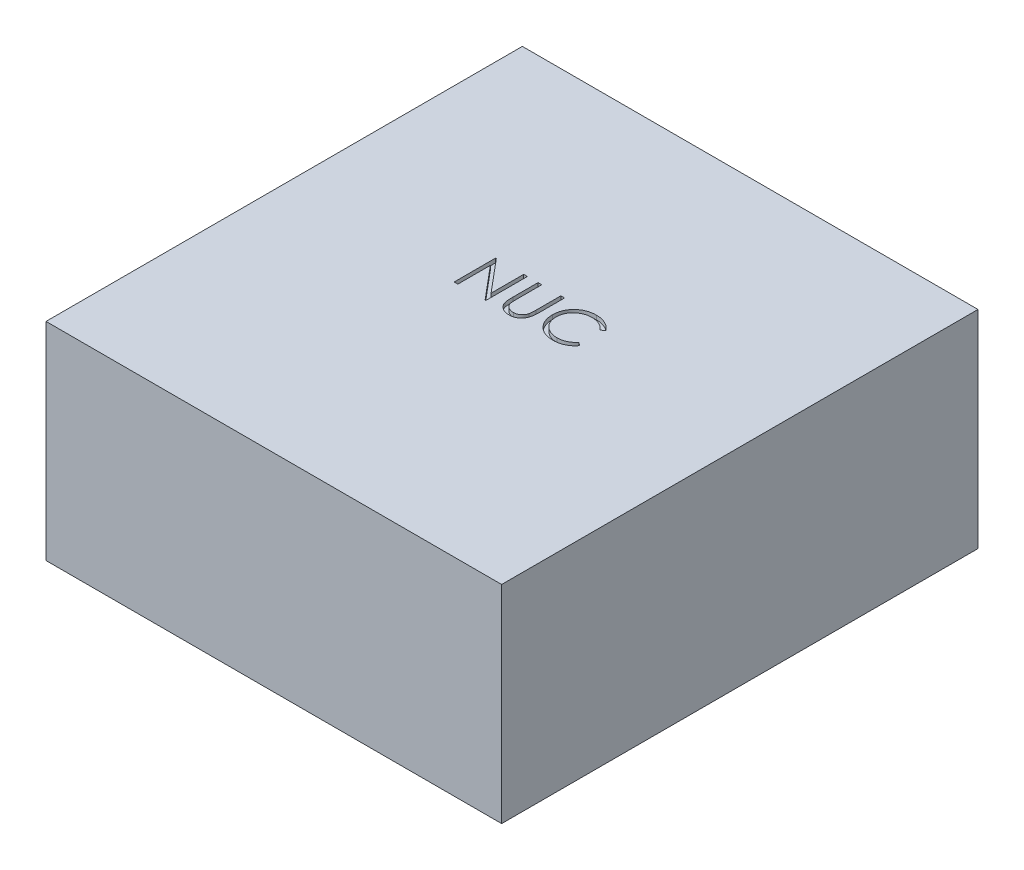
from build123d import *

# Parameters (mm, degrees)
SKETCH1_W           = 110
SKETCH1_H           = 115
BOSS_EXTRUDE1_DEPTH = 50
CUT_EXTRUDE1_DEPTH  = 1


with BuildPart() as part:
    # Sketch1 → Boss-Extrude1 (new body)
    with BuildSketch(Plane(origin=(0, 0, 0), x_dir=(1, 0, 0), z_dir=(0, 1, 0))):
        with Locations((55, 57.5)):
            Rectangle(SKETCH1_W, SKETCH1_H)
    extrude(amount=BOSS_EXTRUDE1_DEPTH)

    # Sketch2 → Cut-Extrude1 (cut)
    with BuildSketch(Plane(origin=(0, 50, 0), x_dir=(1, 0, 0), z_dir=(0, 1, 0))):
        Polygon((41.025641026, 57.5), (41.025641026, 67.5), (41.213942308, 67.5), (47.820512821, 59.629407051), (47.820512821, 67.5), (48.717948718, 67.5), (48.717948718, 57.5), (48.513621795, 57.5), (41.923076923, 65.352564103), (41.923076923, 57.5), align=None)
        with BuildLine():
            Line((51.282051282, 67.5), (52.179487179, 67.5))
            Line((52.179487179, 67.5), (52.179487179, 61.508413462))
            add(Edge.make_bspline(
                [(52.179487179, 61.508413462), (52.179353625, 61.423611359), (52.179100183, 61.262684757), (52.18079308, 61.033632469), (52.185534133, 60.829996872), (52.18852316, 60.650993022), (52.195172684, 60.497442315), (52.200595675, 60.368512856), (52.207568695, 60.264815135), (52.21594903, 60.204298203), (52.219551282, 60.178285256)],
                knots=[0, 0, 0, 0, 1.528628734, 2.90083645, 4.128790002, 5.200304208, 6.127813768, 6.898992206, 7.526736466, 8, 8, 8, 8], degree=3))
            add(Edge.make_bspline(
                [(52.219551282, 60.178285256), (52.234344021, 60.084437361), (52.263095982, 59.902029564), (52.336371348, 59.642291615), (52.438707065, 59.408201735), (52.559972901, 59.192455189), (52.719780362, 59.001057017), (52.911219034, 58.824738009), (53.143155516, 58.670532853), (53.401042961, 58.529530533), (53.679000782, 58.416201727), (53.963032972, 58.3305064), (54.248870055, 58.278280972), (54.440230527, 58.272233718), (54.53525641, 58.269230769)],
                knots=[0, 0, 0, 0, 1.035780045, 2.013197591, 2.933192213, 3.817615948, 4.702609284, 5.640816605, 6.646850145, 7.73207398, 8.84249596, 9.914020372, 10.964143139, 12, 12, 12, 12], degree=3))
            add(Edge.make_bspline(
                [(54.53525641, 58.269230769), (54.616838526, 58.272298913), (54.77953156, 58.278417479), (55.021264219, 58.316307282), (55.256693101, 58.384594613), (55.486980758, 58.472708208), (55.702840713, 58.589129897), (55.904393404, 58.72361801), (56.084290359, 58.88136337), (56.248456067, 59.055935783), (56.391413027, 59.25290664), (56.515330574, 59.467987034), (56.616833231, 59.70441374), (56.666957587, 59.870569232), (56.692708333, 59.955929487)],
                knots=[0, 0, 0, 0, 0.994687771, 1.983630487, 2.973142513, 3.978332533, 4.983357753, 5.956394766, 6.925816176, 7.893390482, 8.871859704, 9.88551698, 10.913711441, 12, 12, 12, 12], degree=3))
            add(Edge.make_bspline(
                [(56.692708333, 59.955929487), (56.70128012, 59.991211128), (56.720381515, 60.069832843), (56.738230215, 60.202750816), (56.756820287, 60.35957757), (56.769719059, 60.541439892), (56.782293974, 60.747728385), (56.789817039, 60.979517692), (56.793294276, 61.235966152), (56.794330506, 61.414929471), (56.794871795, 61.508413462)],
                knots=[0, 0, 0, 0, 0.558680831, 1.244966039, 2.062412453, 2.990489873, 4.051219941, 5.244515665, 6.560634259, 8, 8, 8, 8], degree=3))
            Line((56.794871795, 61.508413462), (56.794871795, 67.5))
            Line((56.794871795, 67.5), (57.692307692, 67.5))
            Line((57.692307692, 67.5), (57.692307692, 61.460336538))
            add(Edge.make_bspline(
                [(57.692307692, 61.460336538), (57.691581634, 61.351484027), (57.690164687, 61.139051733), (57.677877326, 60.827762136), (57.658285898, 60.532467904), (57.630605646, 60.253129342), (57.593928494, 59.99074603), (57.55314215, 59.743018121), (57.501200627, 59.511723856), (57.440533767, 59.295059806), (57.371180772, 59.088815482), (57.28134892, 58.893076583), (57.180136063, 58.701892584), (57.060094197, 58.51815513), (56.925204533, 58.341050692), (56.772485445, 58.171653335), (56.606987842, 58.00725606), (56.425960529, 57.852075871), (56.2323876, 57.709765366), (56.026844864, 57.584628877), (55.810911236, 57.478847113), (55.585148018, 57.391773043), (55.349458867, 57.32630276), (55.103837839, 57.2775166), (54.847725859, 57.24979575), (54.673541127, 57.24567595), (54.585336538, 57.243589744)],
                knots=[0, 0, 0, 0, 1.316592851, 2.569410997, 3.76748051, 4.895814652, 5.963796859, 6.97159953, 7.931736103, 8.829262218, 9.692595152, 10.560224239, 11.431080259, 12.30701507, 13.211635791, 14.121146779, 15.063487852, 16.031507147, 17.00238618, 17.966455255, 18.938106653, 19.907068911, 20.888905087, 21.893141452, 22.933117798, 24, 24, 24, 24], degree=3))
            add(Edge.make_bspline(
                [(54.585336538, 57.243589744), (54.489139102, 57.24583193), (54.300400077, 57.250231092), (54.022291313, 57.275438949), (53.755679324, 57.322920076), (53.497748247, 57.383377058), (53.252009684, 57.466759165), (53.015171271, 57.564182378), (52.791289325, 57.683831694), (52.576731815, 57.816955674), (52.377232511, 57.966740354), (52.194097074, 58.129997994), (52.027023158, 58.304113358), (51.878826883, 58.490971546), (51.747052927, 58.68911928), (51.633538031, 58.899117108), (51.536071619, 59.120883726), (51.485767142, 59.275035727), (51.460336538, 59.352964744)],
                knots=[0, 0, 0, 0, 1.13879206, 2.234305948, 3.301075583, 4.341971843, 5.366689343, 6.369221514, 7.369726634, 8.367512178, 9.355451585, 10.318319045, 11.268648973, 12.207971039, 13.137398894, 14.081662264, 15.030215811, 16, 16, 16, 16], degree=3))
            add(Edge.make_bspline(
                [(51.460336538, 59.352964744), (51.445544658, 59.406200671), (51.41346074, 59.521670582), (51.379102746, 59.712774835), (51.350219656, 59.932817457), (51.323060918, 60.181813509), (51.307035324, 60.459955985), (51.292985499, 60.767124316), (51.281952303, 61.103689921), (51.282017367, 61.338131394), (51.282051282, 61.460336538)],
                knots=[0, 0, 0, 0, 0.625038921, 1.35572334, 2.194682327, 3.136881307, 4.189498639, 5.346923369, 6.617055217, 8, 8, 8, 8], degree=3))
            Line((51.282051282, 61.460336538), (51.282051282, 67.5))
        make_face()
        with BuildLine():
            Line((69.487179487, 65.665064103), (68.701923077, 65.064102564))
            add(Edge.make_bspline(
                [(68.701923077, 65.064102564), (68.645906253, 65.130862478), (68.534627834, 65.263482237), (68.355601541, 65.449709507), (68.169025418, 65.624181683), (67.974970786, 65.78772991), (67.76994473, 65.934634955), (67.558913877, 66.072552392), (67.338348034, 66.1961745), (67.033343077, 66.346068746), (66.634349225, 66.502486332), (66.132078256, 66.633638422), (65.607760832, 66.717127495), (65.250053405, 66.726169899), (65.068108974, 66.730769231)],
                knots=[0, 0, 0, 0, 0.757959112, 1.505699292, 2.245454638, 2.979532153, 3.711538275, 4.438200793, 5.171680507, 5.909471876, 7.393775596, 8.890124382, 10.418191784, 12, 12, 12, 12], degree=3))
            add(Edge.make_bspline(
                [(65.068108974, 66.730769231), (64.967870976, 66.729615052), (64.768325283, 66.727317407), (64.472186787, 66.697005621), (64.18157807, 66.654402163), (63.896688166, 66.591186954), (63.617879713, 66.511265185), (63.343329993, 66.415764003), (63.077013994, 66.297607317), (62.815247599, 66.167012289), (62.564449853, 66.019505304), (62.327149717, 65.858610013), (62.104212666, 65.68612688), (61.895462345, 65.501409433), (61.70068535, 65.305289546), (61.521293033, 65.095677142), (61.357906147, 64.87324236), (61.207286075, 64.640918339), (61.072392551, 64.399381791), (60.959450039, 64.147738733), (60.859435404, 63.890298438), (60.780294711, 63.624152265), (60.717653234, 63.351172934), (60.674431339, 63.070627825), (60.644464278, 62.783103026), (60.642178059, 62.588219276), (60.641025641, 62.489983974)],
                knots=[0, 0, 0, 0, 1.054917814, 2.100044995, 3.131103042, 4.146048494, 5.169673617, 6.183595914, 7.203665975, 8.234915748, 9.262203917, 10.264457458, 11.251630812, 12.227803204, 13.197192746, 14.159520551, 15.12972552, 16.100847026, 17.073214652, 18.039054194, 19.002613845, 19.979014051, 20.95965708, 21.949030935, 22.966165397, 24, 24, 24, 24], degree=3))
            add(Edge.make_bspline(
                [(60.641025641, 62.489983974), (60.644630838, 62.342180203), (60.651709165, 62.051987104), (60.714704405, 61.626928216), (60.810433237, 61.219726291), (60.953906314, 60.832926742), (61.130817887, 60.461760004), (61.354362492, 60.112506138), (61.613266884, 59.779887382), (61.911193797, 59.471764674), (62.238067557, 59.190296887), (62.588775876, 58.942438083), (62.962445269, 58.735824133), (63.354949927, 58.563892857), (63.769310252, 58.431730778), (64.204781116, 58.338690426), (64.660415389, 58.277998481), (64.971756531, 58.272187944), (65.130208333, 58.269230769)],
                knots=[0, 0, 0, 0, 1.029171465, 2.020641659, 2.987623507, 3.938342917, 4.889210282, 5.84687017, 6.821220943, 7.821438502, 8.827599549, 9.822697543, 10.807740252, 11.797342354, 12.80366471, 13.83203677, 14.896651826, 16, 16, 16, 16], degree=3))
            add(Edge.make_bspline(
                [(65.130208333, 58.269230769), (65.304787445, 58.274055854), (65.648400899, 58.283552776), (66.152309545, 58.364007773), (66.634697447, 58.494458967), (67.095590552, 58.677024459), (67.533689541, 58.914353853), (67.949679999, 59.202062075), (68.343913057, 59.542885882), (68.580973864, 59.803123392), (68.701923077, 59.935897436)],
                knots=[0, 0, 0, 0, 1.028121516, 2.023589091, 2.998037872, 3.967518031, 4.937445131, 5.927275754, 6.942489185, 8, 8, 8, 8], degree=3))
            Line((68.701923077, 59.935897436), (69.487179487, 59.340945513))
            add(Edge.make_bspline(
                [(69.487179487, 59.340945513), (69.423984888, 59.259407079), (69.297898387, 59.096720775), (69.093732624, 58.867373033), (68.878654631, 58.651647217), (68.651066889, 58.451282585), (68.413587484, 58.262269826), (68.161952306, 58.08997888), (67.899469356, 57.932004925), (67.627027988, 57.787356569), (67.344917665, 57.659021578), (67.053476423, 57.54915367), (66.753960493, 57.454511128), (66.446356183, 57.376648452), (66.130025449, 57.315873926), (65.806109809, 57.275246284), (65.473910165, 57.247412243), (65.249791819, 57.24487534), (65.136217949, 57.243589744)],
                knots=[0, 0, 0, 0, 0.986787822, 1.968848986, 2.935600012, 3.899624008, 4.868462664, 5.837806735, 6.815139263, 7.798259679, 8.787526145, 9.778297419, 10.776456485, 11.791383307, 12.812564526, 13.85620153, 14.913611965, 16, 16, 16, 16], degree=3))
            add(Edge.make_bspline(
                [(65.136217949, 57.243589744), (65.028664614, 57.244338294), (64.815991214, 57.245818459), (64.501994781, 57.26979608), (64.196310264, 57.302509614), (63.899811333, 57.351767132), (63.610879976, 57.409893817), (63.332135449, 57.487811693), (63.060834848, 57.575095027), (62.79806816, 57.677680703), (62.543611875, 57.793441225), (62.2982867, 57.92427425), (62.062205464, 58.069079578), (61.833047119, 58.224665322), (61.61419688, 58.396029041), (61.403758236, 58.580790854), (61.200551161, 58.778328028), (61.074829204, 58.920770466), (61.01161859, 58.992387821)],
                knots=[0, 0, 0, 0, 1.114604814, 2.203992996, 3.262667896, 4.300477797, 5.318619304, 6.316056647, 7.298880507, 8.271930387, 9.238335007, 10.195173496, 11.151986948, 12.108099108, 13.064862484, 14.031167946, 15.010108607, 16, 16, 16, 16], degree=3))
            add(Edge.make_bspline(
                [(61.01161859, 58.992387821), (60.910373894, 59.116791217), (60.709106817, 59.364096104), (60.451604864, 59.764913194), (60.231183278, 60.18339379), (60.052966362, 60.621736444), (59.913644267, 61.07895755), (59.817126567, 61.555287592), (59.754407697, 62.050281712), (59.747235443, 62.386958251), (59.743589744, 62.558092949)],
                knots=[0, 0, 0, 0, 0.994628077, 1.977248131, 2.950237994, 3.925870899, 4.908910175, 5.911660606, 6.938484602, 8, 8, 8, 8], degree=3))
            add(Edge.make_bspline(
                [(59.743589744, 62.558092949), (59.748033154, 62.737965673), (59.756775286, 63.091854029), (59.831048987, 63.611208181), (59.950531262, 64.108783607), (60.120236658, 64.583651448), (60.335394805, 65.038309392), (60.60118513, 65.469284263), (60.914519822, 65.879332262), (61.272941444, 66.262231551), (61.665990973, 66.612343987), (62.08690187, 66.920361712), (62.53485029, 67.176697472), (63.004901295, 67.390972222), (63.500574671, 67.555670688), (64.020812868, 67.670965507), (64.564638339, 67.742728697), (64.935673841, 67.751800719), (65.124198718, 67.756410256)],
                knots=[0, 0, 0, 0, 1.032925535, 2.032216505, 3.007276963, 3.968222605, 4.92396291, 5.891752235, 6.871517503, 7.883894988, 8.900124299, 9.891468569, 10.874487609, 11.85992873, 12.854644235, 13.869047385, 14.917252991, 16, 16, 16, 16], degree=3))
            add(Edge.make_bspline(
                [(65.124198718, 67.756410256), (65.239097209, 67.755032719), (65.466527201, 67.752306022), (65.802963351, 67.725717044), (66.130512857, 67.681392455), (66.449401377, 67.621060827), (66.76118028, 67.546182766), (67.063466683, 67.448639056), (67.35803436, 67.337106109), (67.643025526, 67.20865335), (67.917072812, 67.06446266), (68.180090865, 66.906132307), (68.429990461, 66.733858577), (68.668530028, 66.549106647), (68.891719203, 66.347967906), (69.105894856, 66.135974775), (69.30378365, 65.907020992), (69.425935636, 65.745864038), (69.487179487, 65.665064103)],
                knots=[0, 0, 0, 0, 1.096760587, 2.17092713, 3.219439832, 4.250915756, 5.268269357, 6.278326846, 7.281116186, 8.274029601, 9.260640565, 10.235837813, 11.203064059, 12.156899882, 13.114053108, 14.069676657, 15.032185724, 16, 16, 16, 16], degree=3))
        make_face()
    extrude(amount=-CUT_EXTRUDE1_DEPTH, mode=Mode.SUBTRACT)


solid = part.part
